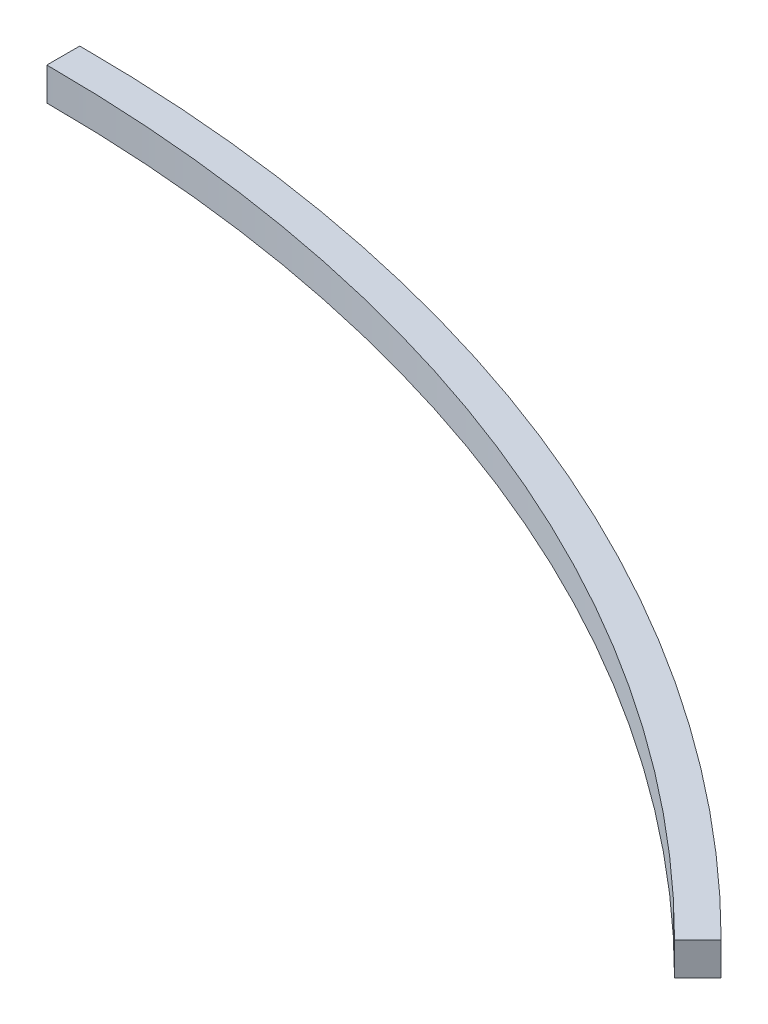
from build123d import *

# Parameters (mm, degrees)
BOSS_EXTRUDE1_DEPTH = 10


with BuildPart() as part:
    # Sketch1 → Boss-Extrude1 (new body)
    with BuildSketch(Plane(origin=(0, 0, 0), x_dir=(1, 0, 0), z_dir=(0, 1, 0))):
        with BuildLine():
            ThreePointArc((0, 470), (179.861213212, 434.22338028), (332.340187158, 332.340187158))
            Line((332.340187158, 332.340187158), (325.269119346, 325.269119346))
            ThreePointArc((325.269119346, 325.269119346), (176.034378888, 424.984584955), (0, 460))
            Line((0, 460), (0, 470))
        make_face()
    extrude(amount=BOSS_EXTRUDE1_DEPTH)


solid = part.part
